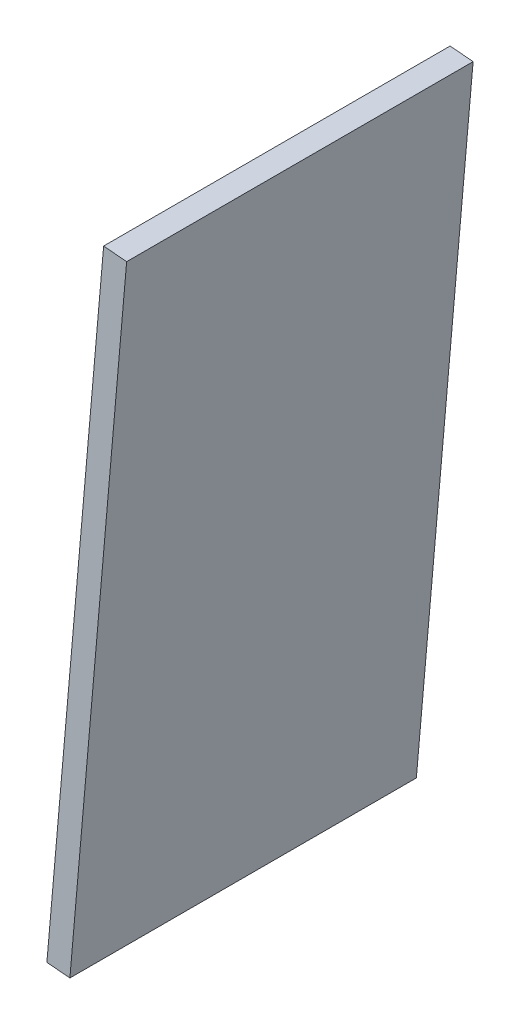
from build123d import *

# Parameters (mm, degrees)
BOSS_EXTRUDE1_DEPTH = 95.25


with BuildPart() as part:
    # Sketch2 → Boss-Extrude1 (new body)
    with BuildSketch(Plane.XY):
        Polygon((38.54300412, 0.531650031), (44.868840453, -0.021788936), (60.472607749, 178.330087371), (54.146771416, 178.883526338), align=None)
    extrude(amount=BOSS_EXTRUDE1_DEPTH)


solid = part.part
